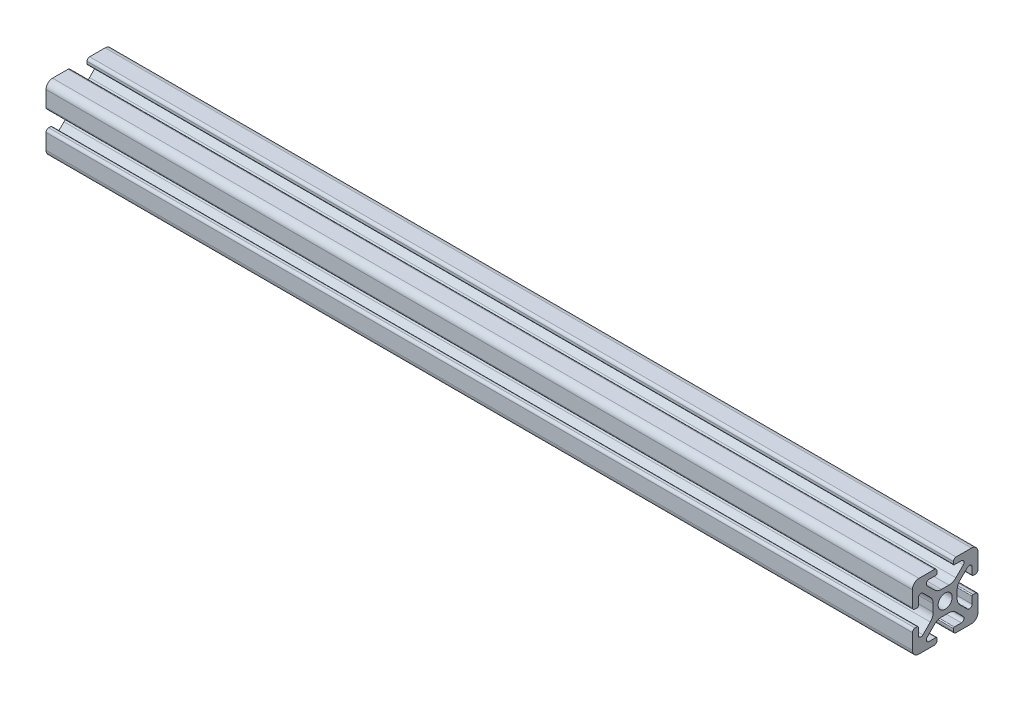
from build123d import *

# Parameters (mm, degrees)
SKIZZE11_R                = 2.15
QUADRATISCH_20X20_1_DEPTH = 264


with BuildPart() as part:
    # Skizze11 → Quadratisch 20X20(1) (new body)
    with BuildSketch(Plane(origin=(-132, 0, 0), x_dir=(0, 0, -1), z_dir=(1, 0, 0))):
        with BuildLine():
            Line((3.3, -10), (8, -10))
            ThreePointArc((8, -10), (9.414213562, -9.414213562), (10, -8))
            Line((10, -8), (10, -3.3))
            ThreePointArc((10, -3.3), (9.765685425, -2.734314575), (9.2, -2.5))
            Line((9.2, -2.5), (8.500000004, -2.5))
            ThreePointArc((8.500000004, -2.5), (8.28786797, -2.587867966), (8.200000004, -2.8))
            Line((8.200000004, -2.8), (8.200000004, -4.91758839))
            ThreePointArc((8.200000004, -4.91758839), (7.686138526, -5.686636439), (6.7789845, -5.506192284))
            Line((6.7789845, -5.506192284), (4.52867966, -3.255887444))
            ThreePointArc((4.52867966, -3.255887444), (3.878361407, -2.282617399), (3.650000005, -1.134567104))
            Line((3.650000005, -1.134567104), (3.650000005, 1.134567116))
            ThreePointArc((3.650000005, 1.134567116), (3.878361407, 2.282617413), (4.528679661, 3.25588746))
            Line((4.528679661, 3.25588746), (6.778984505, 5.506192304))
            ThreePointArc((6.778984505, 5.506192304), (7.686138528, 5.686636458), (8.200000004, 4.917588412))
            Line((8.200000004, 4.917588412), (8.200000004, 2.8))
            ThreePointArc((8.200000004, 2.8), (8.28786797, 2.587867966), (8.500000004, 2.5))
            Line((8.500000004, 2.5), (9.2, 2.5))
            ThreePointArc((9.2, 2.5), (9.765685425, 2.734314575), (10, 3.3))
            Line((10, 3.3), (10, 8))
            ThreePointArc((10, 8), (9.414213562, 9.414213562), (8, 10))
            Line((8, 10), (3.3, 10))
            ThreePointArc((3.3, 10), (2.734314575, 9.765685425), (2.5, 9.2))
            Line((2.5, 9.2), (2.5, 8.5))
            ThreePointArc((2.5, 8.5), (2.587867966, 8.287867966), (2.8, 8.2))
            Line((2.8, 8.2), (4.91758839, 8.2))
            ThreePointArc((4.91758839, 8.2), (5.686636437, 7.686138523), (5.506192283, 6.778984499))
            Line((5.506192283, 6.778984499), (3.255887448, 4.528679664))
            ThreePointArc((3.255887448, 4.528679664), (2.282617404, 3.878361412), (1.134567108, 3.650000009))
            Line((1.134567108, 3.650000009), (-1.134567106, 3.650000009))
            ThreePointArc((-1.134567106, 3.650000009), (-2.282617404, 3.878361412), (-3.25588745, 4.528679666))
            Line((-3.25588745, 4.528679666), (-5.50619229, 6.778984506))
            ThreePointArc((-5.50619229, 6.778984506), (-5.686636444, 7.686138526), (-4.9175884, 8.2))
            Line((-4.9175884, 8.2), (-2.8, 8.2))
            ThreePointArc((-2.8, 8.2), (-2.587867966, 8.287867966), (-2.5, 8.5))
            Line((-2.5, 8.5), (-2.5, 9.2))
            ThreePointArc((-2.5, 9.2), (-2.734314575, 9.765685425), (-3.3, 10))
            Line((-3.3, 10), (-8, 10))
            ThreePointArc((-8, 10), (-9.414213562, 9.414213562), (-10, 8))
            Line((-10, 8), (-10, 3.3))
            ThreePointArc((-10, 3.3), (-9.765685425, 2.734314575), (-9.2, 2.5))
            Line((-9.2, 2.5), (-8.5, 2.5))
            ThreePointArc((-8.5, 2.5), (-8.287867966, 2.587867966), (-8.2, 2.8))
            Line((-8.2, 2.8), (-8.2, 4.9175884))
            ThreePointArc((-8.2, 4.9175884), (-7.686138522, 5.686636449), (-6.778984496, 5.506192294))
            Line((-6.778984496, 5.506192294), (-4.528679665, 3.255887463))
            ThreePointArc((-4.528679665, 3.255887463), (-3.878361412, 2.282617418), (-3.65000001, 1.134567123))
            Line((-3.65000001, 1.134567123), (-3.65000001, -1.134567106))
            ThreePointArc((-3.65000001, -1.134567106), (-3.878361412, -2.282617404), (-4.528679666, -3.25588745))
            Line((-4.528679666, -3.25588745), (-6.778984506, -5.50619229))
            ThreePointArc((-6.778984506, -5.50619229), (-7.686138526, -5.686636444), (-8.2, -4.9175884))
            Line((-8.2, -4.9175884), (-8.2, -2.8))
            ThreePointArc((-8.2, -2.8), (-8.287867966, -2.587867966), (-8.5, -2.5))
            Line((-8.5, -2.5), (-9.2, -2.5))
            ThreePointArc((-9.2, -2.5), (-9.765685425, -2.734314575), (-10, -3.3))
            Line((-10, -3.3), (-10, -8))
            ThreePointArc((-10, -8), (-9.414213562, -9.414213562), (-8, -10))
            Line((-8, -10), (-3.3, -10))
            ThreePointArc((-3.3, -10), (-2.734314575, -9.765685425), (-2.5, -9.2))
            Line((-2.5, -9.2), (-2.5, -8.5))
            ThreePointArc((-2.5, -8.5), (-2.587867966, -8.287867966), (-2.8, -8.2))
            Line((-2.8, -8.2), (-4.9175884, -8.2))
            ThreePointArc((-4.9175884, -8.2), (-5.686636449, -7.686138522), (-5.506192294, -6.778984496))
            Line((-5.506192294, -6.778984496), (-3.255887454, -4.528679656))
            ThreePointArc((-3.255887454, -4.528679656), (-2.282617409, -3.878361403), (-1.134567114, -3.650000001))
            Line((-1.134567114, -3.650000001), (1.134567112, -3.650000001))
            ThreePointArc((1.134567112, -3.650000001), (2.282617409, -3.878361403), (3.255887456, -4.528679657))
            Line((3.255887456, -4.528679657), (5.5061923, -6.778984501))
            ThreePointArc((5.5061923, -6.778984501), (5.686636454, -7.686138524), (4.917588408, -8.2))
            Line((4.917588408, -8.2), (2.8, -8.2))
            ThreePointArc((2.8, -8.2), (2.587867966, -8.287867966), (2.5, -8.5))
            Line((2.5, -8.5), (2.5, -9.2))
            ThreePointArc((2.5, -9.2), (2.734314575, -9.765685425), (3.3, -10))
        make_face()
        Circle(SKIZZE11_R, mode=Mode.SUBTRACT)
    extrude(amount=QUADRATISCH_20X20_1_DEPTH)


solid = part.part
